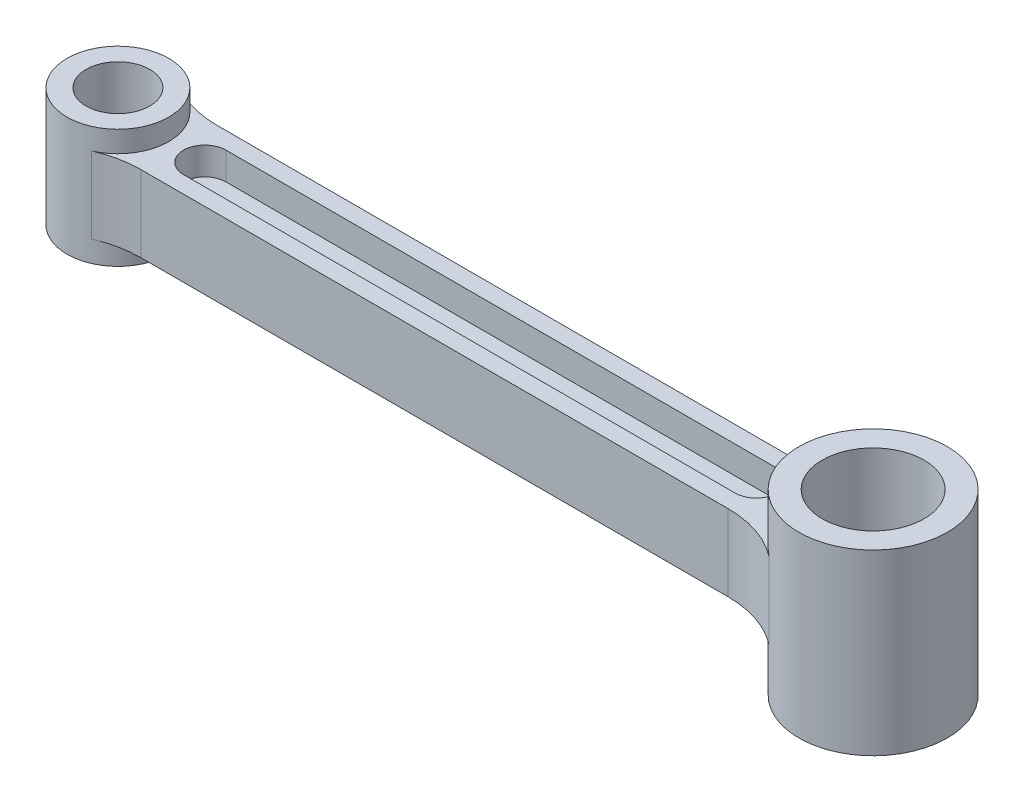
from build123d import *

# Parameters (mm, degrees)
SKETCH2_W            = 178
SKETCH2_H            = 18
BOSS_EXTRUDE1_DEPTH  = 9
SWEEP2_PROFILE_R     = 12
SWEEP3_PROFILE_R     = 17.5
CUT_EXTRUDE1_DEPTH   = 6.5
CUT_SWEEP1_PROFILE_R = 7.5
CUT_SWEEP2_PROFILE_R = 12
FILLET1_R            = 24


with BuildPart() as part:
    # Sketch2 → Boss-Extrude1 (new, symmetric)
    with BuildSketch(Plane.XY):
        with Locations((89, 9)):
            Rectangle(SKETCH2_W, SKETCH2_H)
    extrude(amount=BOSS_EXTRUDE1_DEPTH, both=True)

    # Sweep2: sweep along a path in Sketch11
    with BuildLine(Plane.XY) as sweep2_path:
        Line((0, -5), (0, 23))
    # Sweep2 profile (on start of the path) → Sweep2 (sweep)
    with BuildSketch(Plane(origin=(0, -5, 0), x_dir=(1, 0, 0), z_dir=(0, 1, 0))):
        Circle(SWEEP2_PROFILE_R)
    sweep(path=sweep2_path.line)

    # Sweep3: sweep along a path in Sketch18
    with BuildLine(Plane.XY) as sweep3_path:
        Line((178.00925882, 30), (178.00925882, -12))
    # Sweep3 profile (on start of the path) → Sweep3 (sweep)
    with BuildSketch(Plane(origin=(178.00925882, 30, 0), x_dir=(0, 0, -1), z_dir=(0, -1, 0))):
        Circle(SWEEP3_PROFILE_R)
    sweep(path=sweep3_path.line)

    # Sketch25 → Cut-Extrude1 (cut)
    with BuildSketch(Plane(origin=(0, 18, 0), x_dir=(1, 0, 0), z_dir=(0, 1, 0))):
        with BuildLine():
            Line((20.469090867, 5), (150.469090867, 5))
            ThreePointArc((150.469090867, 5), (155.469090867, 0), (150.469090867, -5))
            Line((150.469090867, -5), (20.469090867, -5))
            ThreePointArc((20.469090867, -5), (15.469090867, 0), (20.469090867, 5))
        make_face()
    cut_extrude1 = extrude(amount=-CUT_EXTRUDE1_DEPTH, mode=Mode.SUBTRACT)

    # Mirror1: Cut-Extrude1 across plane
    add(cut_extrude1.mirror(Plane.ZX.offset(9)), mode=Mode.SUBTRACT)

    # Cut-Sweep1: sweep along a path in Sketch11_2
    with BuildLine(Plane.XY) as cut_sweep1_path:
        Line((0, -5), (0, 23))
    # Cut-Sweep1 profile (on start of the path) → Cut-Sweep1 (sweep, cut)
    with BuildSketch(Plane(origin=(0, -5, 0), x_dir=(1, 0, 0), z_dir=(0, 1, 0))):
        Circle(CUT_SWEEP1_PROFILE_R)
    sweep(path=cut_sweep1_path.line, mode=Mode.SUBTRACT)

    # Cut-Sweep2: sweep along a path in Sketch18_2
    with BuildLine(Plane.XY) as cut_sweep2_path:
        Line((178.00925882, 30), (178.00925882, -12))
    # Cut-Sweep2 profile (on start of the path) → Cut-Sweep2 (sweep, cut)
    with BuildSketch(Plane(origin=(178.00925882, 30, 0), x_dir=(0, 0, -1), z_dir=(0, -1, 0))):
        Circle(CUT_SWEEP2_PROFILE_R)
    sweep(path=cut_sweep2_path.line, mode=Mode.SUBTRACT)

    # Fillet1
    fillet1_edges = [part.edges().sort_by_distance(p)[0] for p in [
        (163.0009278, 9, 9),
        (163.0009278, 9, -9),
        (7.937253933, 9, -9),
        (7.937253933, 9, 9),
    ]]
    fillet(fillet1_edges, radius=FILLET1_R)


solid = part.part
